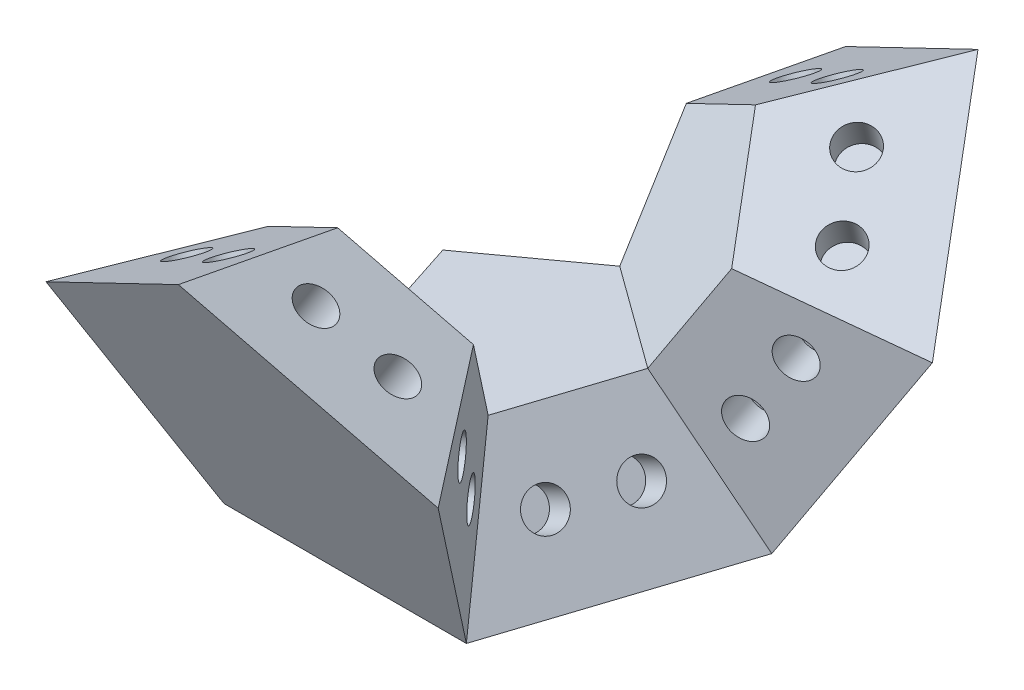
from build123d import *

# Parameters (mm, degrees)
BOSS_EXTRUDE1_DEPTH     = 6.752040791
BOSS_EXTRUDE1_TAPER     = 31.717474411
SKETCH3_R               = 1
CUT_EXTRUDE1_DEPTH      = 2
CIRPATTERN1_COUNT       = 5
MIRROR3_COPY_1_SKETCH_R = 1
MIRROR3_COPY_1_DEPTH    = 2
MIRROR3_COPY_2_SKETCH_R = 1
MIRROR3_COPY_2_DEPTH    = 2
MIRROR3_COPY_3_SKETCH_R = 1
MIRROR3_COPY_3_DEPTH    = 2
MIRROR3_COPY_4_SKETCH_R = 1
MIRROR3_COPY_4_DEPTH    = 2
MIRROR5_COPY_1_SKETCH_R = 1
MIRROR5_COPY_1_DEPTH    = 2
MIRROR5_COPY_2_SKETCH_R = 1
MIRROR5_COPY_2_DEPTH    = 2
MIRROR5_COPY_3_SKETCH_R = 1
MIRROR5_COPY_3_DEPTH    = 2
MIRROR5_COPY_4_SKETCH_R = 1
MIRROR5_COPY_4_DEPTH    = 2


with BuildPart() as part:
    # Sketch1 → Boss-Extrude1 (new body)
    with BuildSketch(Plane(origin=(0, 0, 0), x_dir=(1, 0, 0), z_dir=(0, 1, 0))):
        Polygon((0, 10.803265266), (-10.274515829, 3.338392562), (-6.35, -8.740025195), (6.35, -8.740025195), (10.274515829, 3.338392562), align=None)
    boss_extrude1 = extrude(amount=BOSS_EXTRUDE1_DEPTH, taper=BOSS_EXTRUDE1_TAPER)

    # Sketch3 → Cut-Extrude1 (cut)
    with BuildSketch(Plane(origin=(0, 3.908658092, 6.324341644), x_dir=(1, 0, 0), z_dir=(1.6266940928737823e-15, 0.5257311121191348, 0.8506508083520392))):
        with Locations((-2, -0.626153166)):
            Circle(SKETCH3_R)
        with Locations((2, -0.626153166)):
            Circle(SKETCH3_R)
    cut_extrude1 = extrude(amount=-CUT_EXTRUDE1_DEPTH, mode=Mode.SUBTRACT)

    # CirPattern1: Cut-Extrude1 ×5 about axis
    cirpattern1_axis = Axis((0, 14.848740719, 0), (0, -1, 0))
    for i in range(1, CIRPATTERN1_COUNT):
        add(cut_extrude1.rotate(cirpattern1_axis, i * 360 / CIRPATTERN1_COUNT), mode=Mode.SUBTRACT)

    # Mirror3: Boss-Extrude1, Cut-Extrude1 across plane
    add(boss_extrude1.mirror(Plane(origin=(-6.35, 0, 8.740025195), x_dir=(-2.6320463315684497e-15, -0.8506508083520393, 0.5257311121191345), z_dir=(1.6266940928737817e-15, 0.5257311121191347, 0.8506508083520393))))
    add(cut_extrude1.mirror(Plane(origin=(-6.35, 0, 8.740025195), x_dir=(-2.6320463315684497e-15, -0.8506508083520393, 0.5257311121191345), z_dir=(1.6266940928737817e-15, 0.5257311121191347, 0.8506508083520393))), mode=Mode.SUBTRACT)

    # Mirror3 copy 1 sketch → Mirror3 copy 1 (cut)
    with BuildSketch(Plane(origin=(-6.014806331, 7.817316184, 8.27867069), x_dir=(0.3090169943749462, -0.8506508083520415, -0.4253254041760179), z_dir=(-0.8090169943749479, 0, -0.5877852522924727))):
        with Locations((-2, 0.626153166)):
            Circle(MIRROR3_COPY_1_SKETCH_R)
        with Locations((2, 0.626153166)):
            Circle(MIRROR3_COPY_1_SKETCH_R)
    extrude(amount=-MIRROR3_COPY_1_DEPTH, mode=Mode.SUBTRACT)

    # Mirror3 copy 2 sketch → Mirror3 copy 2 (cut)
    with BuildSketch(Plane(origin=(-3.717354749, 14.141657828, 11.440841512), x_dir=(-0.8090169943749482, -0.5257311121191344, -0.26286555605956313), z_dir=(-0.5, 0.8506508083520394, -0.1624598481164556))):
        with Locations((-2, 0.626153166)):
            Circle(MIRROR3_COPY_2_SKETCH_R)
        with Locations((2, 0.626153166)):
            Circle(MIRROR3_COPY_2_SKETCH_R)
    extrude(amount=-MIRROR3_COPY_2_DEPTH, mode=Mode.SUBTRACT)

    # Mirror3 copy 3 sketch → Mirror3 copy 3 (cut)
    with BuildSketch(Plane(origin=(3.717354749, 14.141657828, 11.440841512), x_dir=(-0.8090169943749467, 0.5257311121191343, 0.262865556059568), z_dir=(0.4999999999999991, 0.8506508083520395, -0.16245984811645744))):
        with Locations((-2, 0.626153166)):
            Circle(MIRROR3_COPY_3_SKETCH_R)
        with Locations((2, 0.626153166)):
            Circle(MIRROR3_COPY_3_SKETCH_R)
    extrude(amount=-MIRROR3_COPY_3_DEPTH, mode=Mode.SUBTRACT)

    # Mirror3 copy 4 sketch → Mirror3 copy 4 (cut)
    with BuildSketch(Plane(origin=(6.014806331, 7.817316184, 8.27867069), x_dir=(0.3090169943749485, 0.8506508083520405, 0.42532540417601816), z_dir=(0.8090169943749456, 0, -0.5877852522924757))):
        with Locations((-2, 0.626153166)):
            Circle(MIRROR3_COPY_4_SKETCH_R)
        with Locations((2, 0.626153166)):
            Circle(MIRROR3_COPY_4_SKETCH_R)
    extrude(amount=-MIRROR3_COPY_4_DEPTH, mode=Mode.SUBTRACT)

    # Mirror5: Boss-Extrude1, Cut-Extrude1 across plane
    add(boss_extrude1.mirror(Plane(origin=(10.274515829, 0, -3.338392562), x_dir=(0.4742680099309791, 0.49867489660708614, 0.7255296012224591), z_dir=(0.4999999999999987, 0.5257311121191346, -0.688190960235587))))
    add(cut_extrude1.mirror(Plane(origin=(10.274515829, 0, -3.338392562), x_dir=(0.4742680099309791, 0.49867489660708614, 0.7255296012224591), z_dir=(0.4999999999999987, 0.5257311121191346, -0.688190960235587))), mode=Mode.SUBTRACT)

    # Mirror5 copy 1 sketch → Mirror5 copy 1 (cut)
    with BuildSketch(Plane(origin=(3.717354749, 14.141657828, -11.440841512), x_dir=(0.8090169943749475, 0.5257311121191339, 0.26286555605956596), z_dir=(-0.5000000000000014, 0.8506508083520399, -0.16245984811644945))):
        with Locations((-2, 0.626153166)):
            Circle(MIRROR5_COPY_1_SKETCH_R)
        with Locations((2, 0.626153166)):
            Circle(MIRROR5_COPY_1_SKETCH_R)
    extrude(amount=-MIRROR5_COPY_1_DEPTH, mode=Mode.SUBTRACT)

    # Mirror5 copy 2 sketch → Mirror5 copy 2 (cut)
    with BuildSketch(Plane(origin=(0, 7.817316184, -10.232999736), x_dir=(-1.2043746199203667e-15, 0.8506508083520407, -0.5257311121191327), z_dir=(-1, 0, 0))):
        with Locations((-2, 0.626153166)):
            Circle(MIRROR5_COPY_2_SKETCH_R)
        with Locations((2, 0.626153166)):
            Circle(MIRROR5_COPY_2_SKETCH_R)
    extrude(amount=-MIRROR5_COPY_2_DEPTH, mode=Mode.SUBTRACT)

    # Mirror5 copy 3 sketch → Mirror5 copy 3 (cut)
    with BuildSketch(Plane(origin=(3.717354749, 3.908658092, -5.116499868), x_dir=(-0.8090169943749478, 0, -0.5877852522924727), z_dir=(-0.4999999999999993, -0.5257311121191345, 0.6881909602355869))):
        with Locations((-2, 0.626153166)):
            Circle(MIRROR5_COPY_3_SKETCH_R)
        with Locations((2, 0.626153166)):
            Circle(MIRROR5_COPY_3_SKETCH_R)
    extrude(amount=-MIRROR5_COPY_3_DEPTH, mode=Mode.SUBTRACT)

    # Mirror5 copy 4 sketch → Mirror5 copy 4 (cut)
    with BuildSketch(Plane(origin=(9.73216108, 7.817316184, -3.162170822), x_dir=(-0.4999999999999984, -0.8506508083520413, 0.1624598481164517), z_dir=(0.3090169943749473, -1.1894596157351711e-15, 0.9510565162951536))):
        with Locations((-2, 0.626153166)):
            Circle(MIRROR5_COPY_4_SKETCH_R)
        with Locations((2, 0.626153166)):
            Circle(MIRROR5_COPY_4_SKETCH_R)
    extrude(amount=-MIRROR5_COPY_4_DEPTH, mode=Mode.SUBTRACT)


solid = part.part
